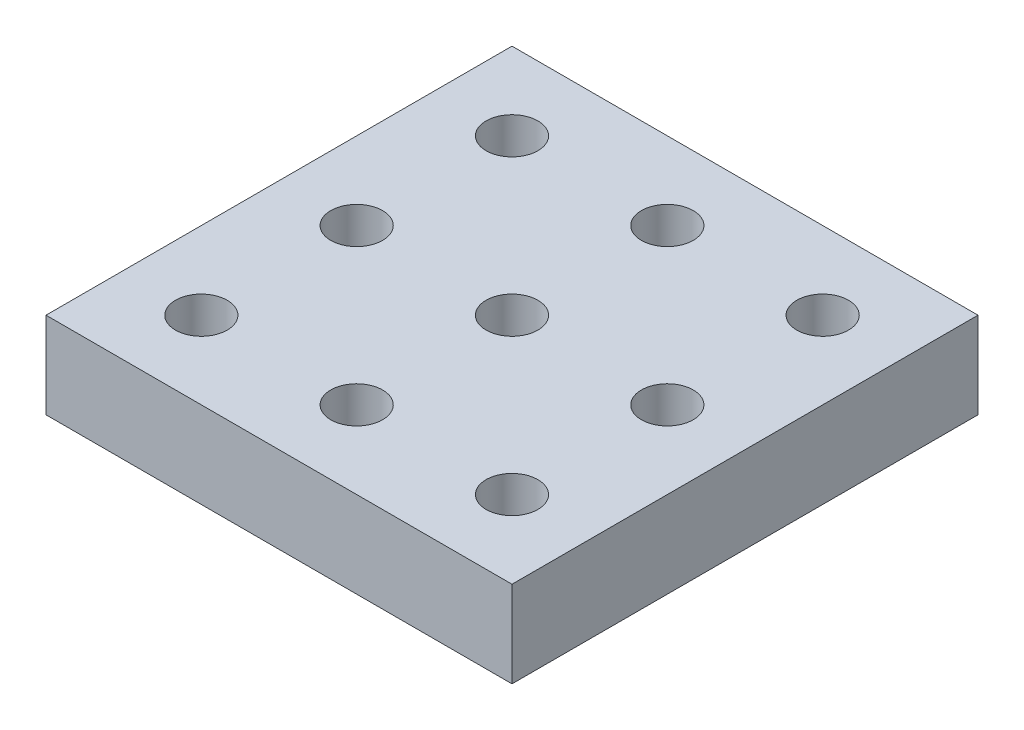
from build123d import *

# Parameters (mm, degrees)
SKETCH1_W           = 54
SKETCH1_H           = 54
SKETCH1_R           = 3
BOSS_EXTRUDE1_DEPTH = 10


with BuildPart() as part:
    # Sketch1 → Boss-Extrude1 (new body)
    with BuildSketch(Plane(origin=(0, 0, 0), x_dir=(1, 0, 0), z_dir=(0, 1, 0))):
        Rectangle(SKETCH1_W, SKETCH1_H)
        with Locations((-18, -18)):
            Circle(SKETCH1_R, mode=Mode.SUBTRACT)
        with Locations((0, -18)):
            Circle(SKETCH1_R, mode=Mode.SUBTRACT)
        with Locations((18, -18)):
            Circle(SKETCH1_R, mode=Mode.SUBTRACT)
        with Locations((18, 0)):
            Circle(SKETCH1_R, mode=Mode.SUBTRACT)
        with Locations((18, 18)):
            Circle(SKETCH1_R, mode=Mode.SUBTRACT)
        with Locations((0, 18)):
            Circle(SKETCH1_R, mode=Mode.SUBTRACT)
        with Locations((-18, 18)):
            Circle(SKETCH1_R, mode=Mode.SUBTRACT)
        with Locations((-18, 0)):
            Circle(SKETCH1_R, mode=Mode.SUBTRACT)
        Circle(SKETCH1_R, mode=Mode.SUBTRACT)
    extrude(amount=BOSS_EXTRUDE1_DEPTH)


solid = part.part
